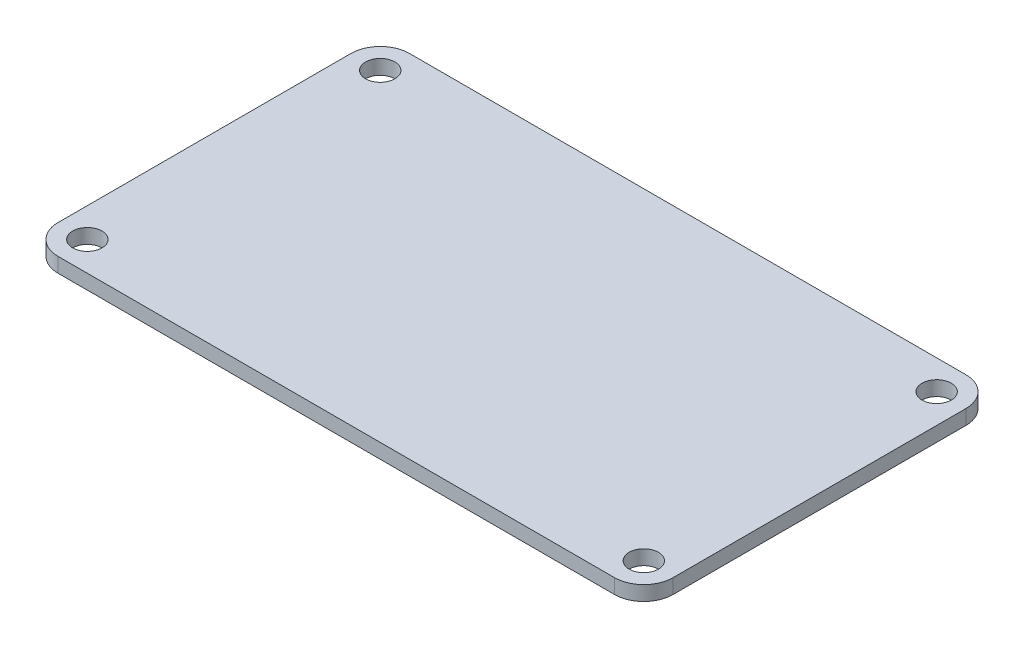
from build123d import *

# Parameters (mm, degrees)
SKETCH1_W           = 42
SKETCH1_H           = 24
BOSS_EXTRUDE1_DEPTH = 1
SKETCH2_R           = 1
CUT_EXTRUDE1_DEPTH  = 2
FILLET1_R           = 2


with BuildPart() as part:
    # Sketch1 → Boss-Extrude1 (new body)
    with BuildSketch(Plane(origin=(0, 0, 0), x_dir=(1, 0, 0), z_dir=(0, 1, 0))):
        Rectangle(SKETCH1_W, SKETCH1_H)
    extrude(amount=BOSS_EXTRUDE1_DEPTH)

    # Sketch2 → Cut-Extrude1 (cut, through all)
    with BuildSketch(Plane(origin=(0, 1, 0), x_dir=(1, 0, 0), z_dir=(0, 1, 0))):
        with Locations((-19, 10)):
            Circle(SKETCH2_R)
        with Locations((-19, -10)):
            Circle(SKETCH2_R)
        with Locations((19, -10)):
            Circle(SKETCH2_R)
        with Locations((19, 10)):
            Circle(SKETCH2_R)
    extrude(amount=-CUT_EXTRUDE1_DEPTH, mode=Mode.SUBTRACT)

    # Fillet1
    fillet1_edges = [part.edges().sort_by_distance(p)[0] for p in [
        (21, 0.5, 12),
        (-21, 0.5, 12),
        (-21, 0.5, -12),
        (21, 0.5, -12),
    ]]
    fillet(fillet1_edges, radius=FILLET1_R)


solid = part.part
